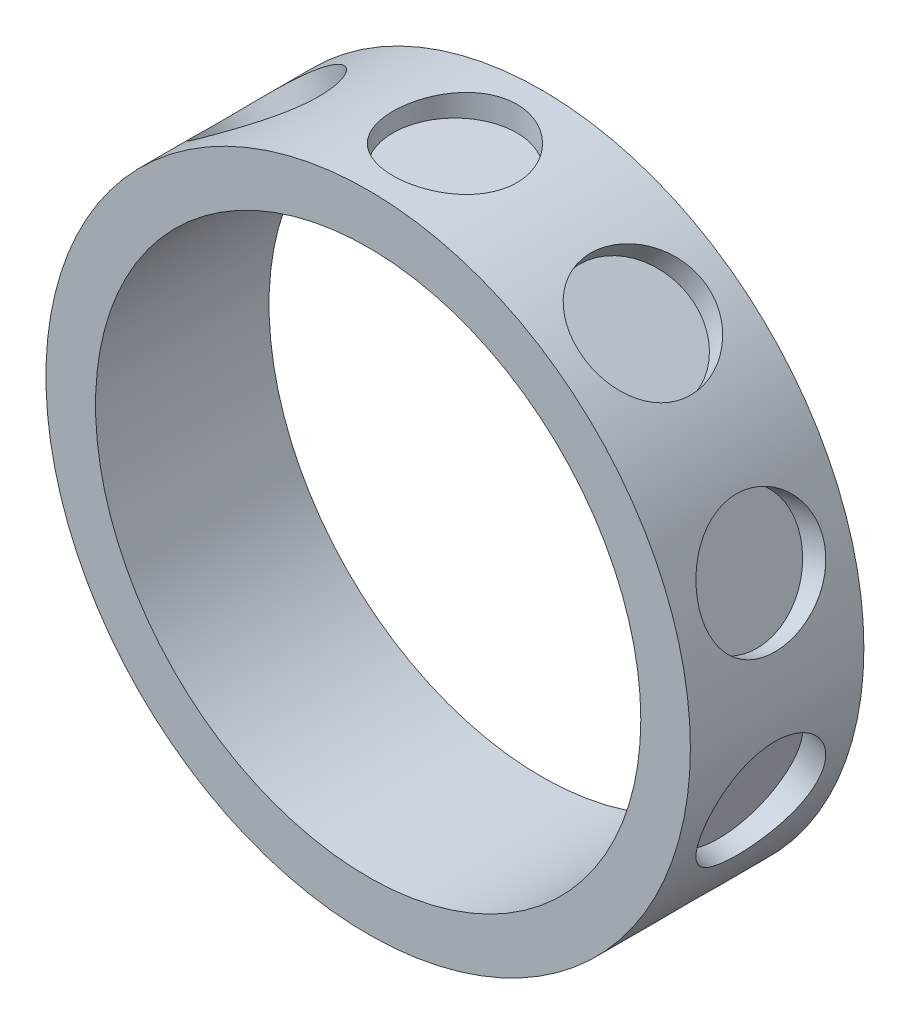
from build123d import *

# Parameters (mm, degrees)
SKETCH1_R           = 13
SKETCH1_R_2         = 11
BOSS_EXTRUDE1_DEPTH = 3.5
SKETCH2_R           = 2.5
CUT_EXTRUDE3_DEPTH  = 1
CIRPATTERN1_COUNT   = 10


with BuildPart() as part:
    # Sketch1 → Boss-Extrude1 (new, symmetric)
    with BuildSketch(Plane.XY):
        Circle(SKETCH1_R)
        Circle(SKETCH1_R_2, mode=Mode.SUBTRACT)
    extrude(amount=BOSS_EXTRUDE1_DEPTH, both=True)

    # Sketch2 → Cut-Extrude3 (cut)
    with BuildSketch(Plane(origin=(0, 13, 0), x_dir=(1, 0, 0), z_dir=(0, 1, 0))):
        Circle(SKETCH2_R)
    cut_extrude3 = extrude(amount=-CUT_EXTRUDE3_DEPTH, mode=Mode.SUBTRACT)

    # CirPattern1: Cut-Extrude3 ×10 about axis
    cirpattern1_axis = Axis((0, 0, 3.5), (0, 0, -1))
    for i in range(1, CIRPATTERN1_COUNT):
        add(cut_extrude3.rotate(cirpattern1_axis, i * 360 / CIRPATTERN1_COUNT), mode=Mode.SUBTRACT)


solid = part.part
